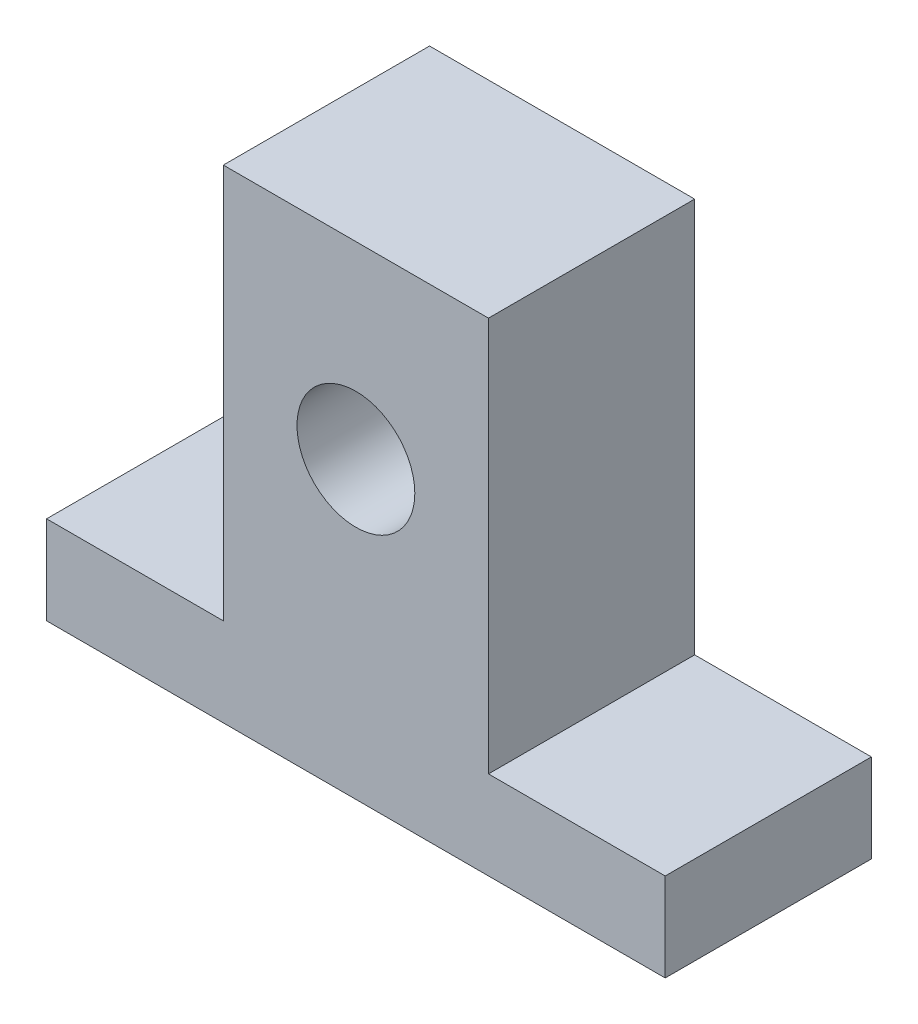
from build123d import *

# Parameters (mm, degrees)
SKETCH2_R           = 4
BOSS_EXTRUDE1_DEPTH = 14


with BuildPart() as part:
    # Sketch2 → Boss-Extrude1 (new body)
    with BuildSketch(Plane.XY):
        Polygon((0, 0), (42, 0), (42, 6), (30, 6), (30, 32.8), (12, 32.8), (12, 6), (0, 6), align=None)
        with Locations((21, 20)):
            Circle(SKETCH2_R, mode=Mode.SUBTRACT)
    extrude(amount=BOSS_EXTRUDE1_DEPTH)


solid = part.part
